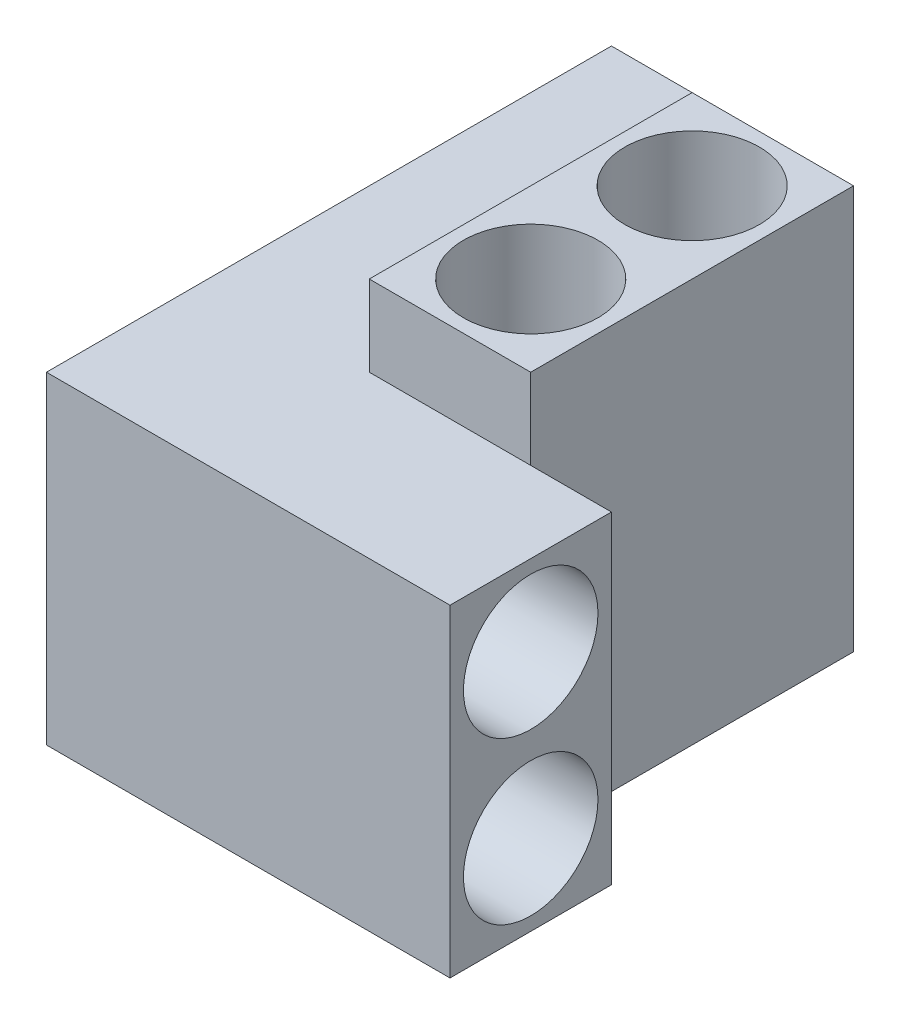
from build123d import *

# Parameters (mm, degrees)
SKETCH1_W                = 6.35
SKETCH1_H                = 15.875
SKETCH1_W_2              = 15.875
SKETCH1_H_2              = 6.35
BOSS_EXTRUDE1_DEPTH      = 6.35
SKETCH5_R                = 2.645833291
CUT_EXTRUDE1_DEPTH       = 12.7
SKETCH6_R                = 2.645833333
CUT_EXTRUDE2_DEPTH       = 12.7
SKETCH10_W               = 6.35
SKETCH10_H               = 15.875
BOSS_EXTRUDE5_DEPTH      = 6.35
SKETCH11_R               = 2.645833333
CUT_EXTRUDE5_DEPTH       = 12.7
SKETCH12_R               = 2.645833333
CUT_EXTRUDE6_DEPTH       = 12.7
SKETCH13_W               = 6.35
SKETCH13_H               = 12.7
BOSS_EXTRUDE6_DEPTH      = 3.175
BOSS_EXTRUDE6_DEPTH_BACK = 12.7
SKETCH14_R               = 2.645833333
CUT_EXTRUDE7_DEPTH       = 12.7


with BuildPart() as part:
    # Sketch1 → Boss-Extrude1 (new body)
    with BuildSketch(Plane(origin=(0, 0, 0), x_dir=(1, 0, 0), z_dir=(0, 1, 0))):
        with Locations((3.175, 14.2875)):
            Rectangle(SKETCH1_W, SKETCH1_H)
        with Locations((7.9375, 3.175)):
            Rectangle(SKETCH1_W_2, SKETCH1_H_2)
    extrude(amount=BOSS_EXTRUDE1_DEPTH)

    # Sketch5 → Cut-Extrude1 (cut)
    with BuildSketch(Plane(origin=(15.875, 0, 0), x_dir=(0, 0, -1), z_dir=(1, 0, 0))):
        with Locations((3.175, 3.175)):
            Circle(SKETCH5_R)
    extrude(amount=-CUT_EXTRUDE1_DEPTH, mode=Mode.SUBTRACT)

    # Sketch6 → Cut-Extrude2 (cut)
    with BuildSketch(Plane(origin=(0, 0, -22.225), x_dir=(-1, 0, 0), z_dir=(0, 0, -1))):
        with Locations((-3.175, 3.175)):
            Circle(SKETCH6_R)
    extrude(amount=-CUT_EXTRUDE2_DEPTH, mode=Mode.SUBTRACT)

    # Sketch10 → Boss-Extrude5 (add)
    with BuildSketch(Plane(origin=(0, 6.35, 0), x_dir=(1, 0, 0), z_dir=(0, 1, 0))):
        with Locations((3.175, 14.2875)):
            Rectangle(SKETCH10_W, SKETCH10_H)
        Polygon((0, 6.35), (0, 0), (15.875, 0), (15.875, 6.35), (6.35, 6.35), align=None)
    extrude(amount=BOSS_EXTRUDE5_DEPTH)

    # Sketch11 → Cut-Extrude5 (cut)
    with BuildSketch(Plane(origin=(15.875, 0, 0), x_dir=(0, 0, -1), z_dir=(1, 0, 0))):
        with Locations((3.175, 9.525)):
            Circle(SKETCH11_R)
    extrude(amount=-CUT_EXTRUDE5_DEPTH, mode=Mode.SUBTRACT)

    # Sketch12 → Cut-Extrude6 (cut)
    with BuildSketch(Plane(origin=(0, 0, -22.225), x_dir=(-1, 0, 0), z_dir=(0, 0, -1))):
        with Locations((-3.175, 9.525)):
            Circle(SKETCH12_R)
    extrude(amount=-CUT_EXTRUDE6_DEPTH, mode=Mode.SUBTRACT)

    # Sketch13 → Boss-Extrude6 (add, two sides)
    with BuildSketch(Plane(origin=(0, 12.7, 0), x_dir=(1, 0, 0), z_dir=(0, 1, 0))) as boss_extrude6_sk:
        with Locations((9.525, 12.7)):
            Rectangle(SKETCH13_W, SKETCH13_H)
    extrude(amount=BOSS_EXTRUDE6_DEPTH)
    extrude(boss_extrude6_sk.sketch, amount=-BOSS_EXTRUDE6_DEPTH_BACK)

    # Sketch14 → Cut-Extrude7 (cut)
    with BuildSketch(Plane(origin=(0, 15.875, 0), x_dir=(1, 0, 0), z_dir=(0, 1, 0))):
        with Locations((9.525, 9.525)):
            Circle(SKETCH14_R)
        with Locations((9.525, 15.875)):
            Circle(SKETCH14_R)
    extrude(amount=-CUT_EXTRUDE7_DEPTH, mode=Mode.SUBTRACT)


solid = part.part
